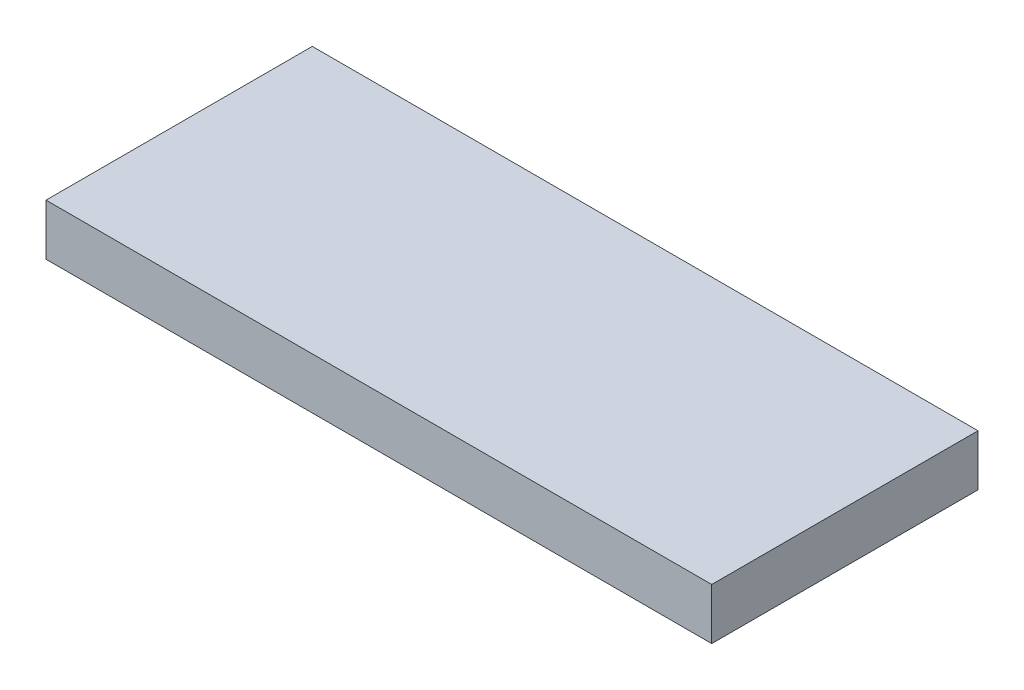
from build123d import *

# Parameters (mm, degrees)
SKETCH1_W           = 82.55
SKETCH1_H           = 33.02
BOSS_EXTRUDE1_DEPTH = 6.35


with BuildPart() as part:
    # Sketch1 → Boss-Extrude1 (new body)
    with BuildSketch(Plane(origin=(0, 0, 0), x_dir=(1, 0, 0), z_dir=(0, 1, 0))):
        Rectangle(SKETCH1_W, SKETCH1_H)
    extrude(amount=BOSS_EXTRUDE1_DEPTH)


solid = part.part
